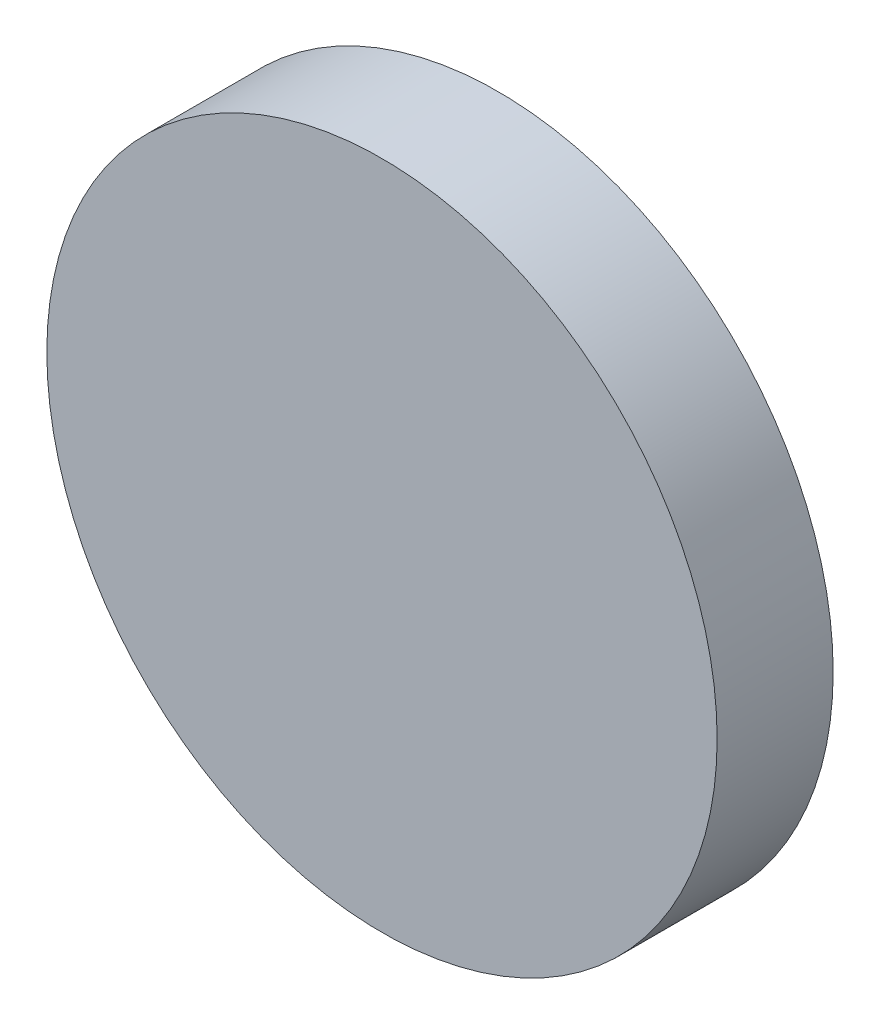
from build123d import *

# Parameters (mm, degrees)
SKETCH1_R           = 65
BOSS_EXTRUDE1_DEPTH = 22.5


with BuildPart() as part:
    # Sketch1 → Boss-Extrude1 (new body)
    with BuildSketch(Plane.XY):
        Circle(SKETCH1_R)
    extrude(amount=BOSS_EXTRUDE1_DEPTH)


solid = part.part
